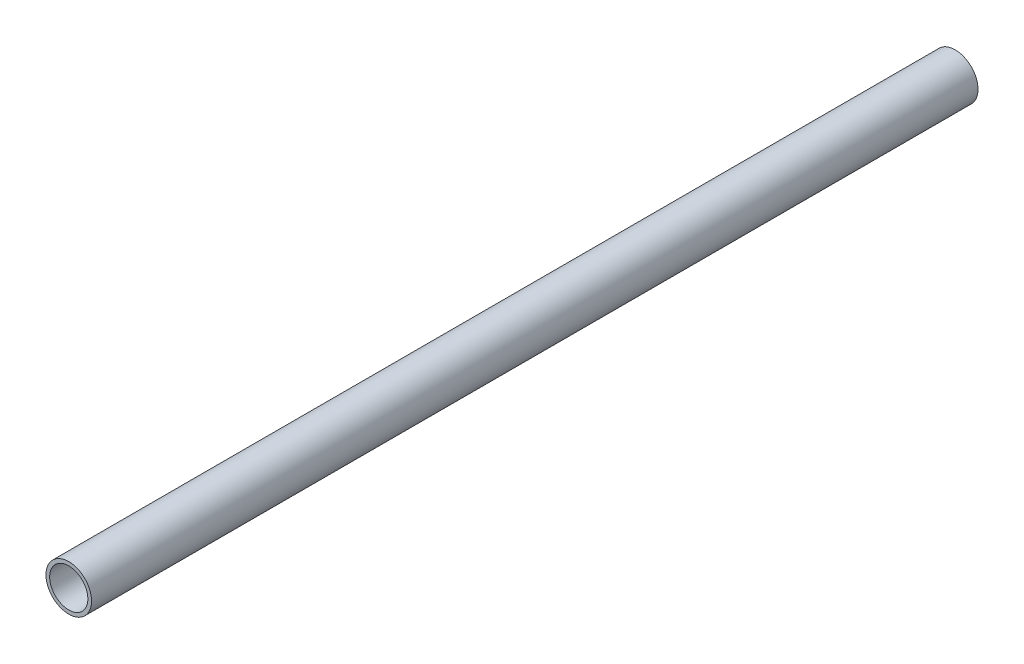
from build123d import *

# Parameters (mm, degrees)
SZKIC1_R                         = 8.35
SZKIC1_R_2                       = 7
DODANIE_WYCI_GNI_CIE1_DEPTH      = 315
DODANIE_WYCI_GNI_CIE1_DEPTH_BACK = 9.717713


with BuildPart() as part:
    # Szkic1 → Dodanie-wyciągnięcie1 (new body, two sides)
    with BuildSketch(Plane.XY) as dodanie_wyci_gni_cie1_sk:
        Circle(SZKIC1_R)
        Circle(SZKIC1_R_2, mode=Mode.SUBTRACT)
    extrude(amount=DODANIE_WYCI_GNI_CIE1_DEPTH)
    extrude(dodanie_wyci_gni_cie1_sk.sketch, amount=-DODANIE_WYCI_GNI_CIE1_DEPTH_BACK)


solid = part.part
